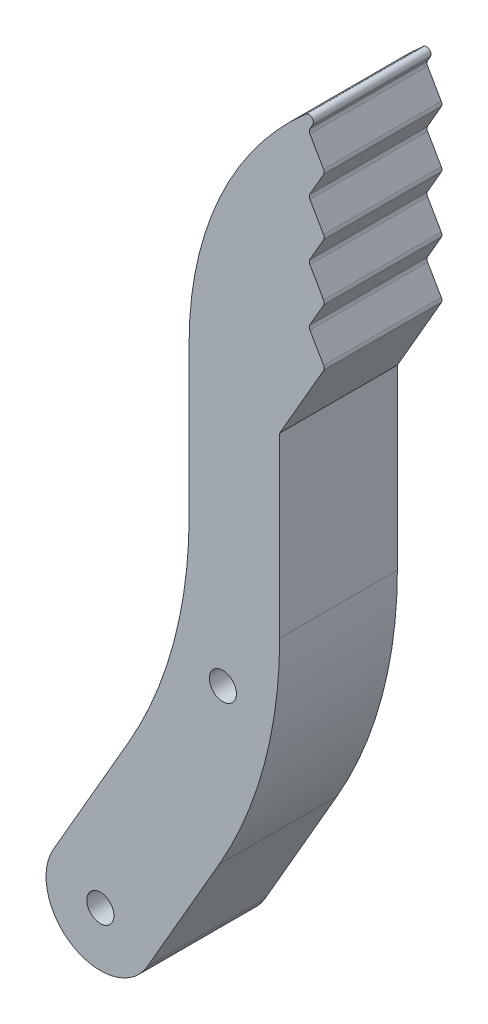
from build123d import *

# Parameters (mm, degrees)
SKETCH1_R           = 1.5
BOSS_EXTRUDE1_DEPTH = 6.5
FILLET1_R           = 0.5


with BuildPart() as part:
    # Sketch1 → Boss-Extrude1 (new body, symmetric)
    with BuildSketch(Plane.XY):
        with BuildLine():
            Line((0, 25), (-5, 16.339745962))
            Line((-5, 16.339745962), (-5, -3.282032303))
            ThreePointArc((-5, -3.282032303), (-6.703708686, -16.222984558), (-11.698729811, -28.282032303))
            Line((-11.698729811, -28.282032303), (-19.607695155, -41.980762114))
            ThreePointArc((-19.607695155, -41.980762114), (-27.803847577, -44.176914536), (-30, -35.980762114))
            Line((-30, -35.980762114), (-21.698729811, -21.602540378))
            ThreePointArc((-21.698729811, -21.602540378), (-16.703708686, -9.543492634), (-15, 3.397459622))
            Line((-15, 3.397459622), (-15, 20))
            ThreePointArc((-15, 20), (-11.041019662, 36.770509831), (0, 50))
            Line((0, 50), (-1.804219591, 46.875))
            Line((-1.804219591, 46.875), (0, 43.75))
            Line((0, 43.75), (-1.804219591, 40.625))
            Line((-1.804219591, 40.625), (0, 37.5))
            Line((0, 37.5), (-1.804219591, 34.375))
            Line((-1.804219591, 34.375), (0, 31.25))
            Line((0, 31.25), (-1.804219591, 28.125))
            Line((-1.804219591, 28.125), (0, 25))
        make_face()
        with Locations((-24.803847577, -38.980762114)):
            Circle(SKETCH1_R, mode=Mode.SUBTRACT)
        with Locations((-11.275914322, -10.99786575)):
            Circle(SKETCH1_R, mode=Mode.SUBTRACT)
    extrude(amount=BOSS_EXTRUDE1_DEPTH, both=True)

    # Fillet1
    fillet1_edges = [part.edges().sort_by_distance(p)[0] for p in [
        (0, 50, 0),
        (-1.804219591, 46.875, 0),
        (0, 43.75, 0),
        (-1.804219591, 40.625, 0),
        (0, 37.5, 0),
        (-1.804219591, 34.375, 0),
        (0, 31.25, 0),
        (-1.804219591, 28.125, 0),
        (0, 25, 0),
    ]]
    fillet(fillet1_edges, radius=FILLET1_R)


solid = part.part
